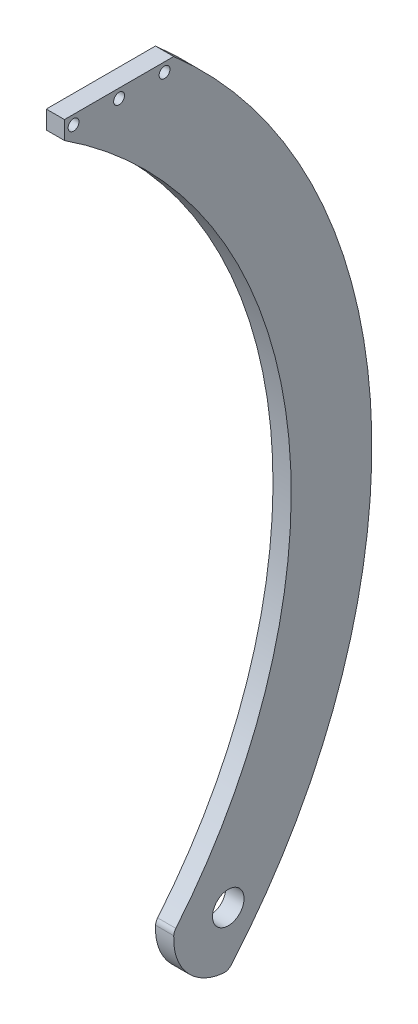
from build123d import *

# Parameters (mm, degrees)
SKETCH1_R                 = 5.5
BOSS_EXTRUDE1_DEPTH       = 6.35
F_6_CLEARANCE_HOLE1_D     = 3.7973
F_6_CLEARANCE_HOLE1_DEPTH = 6.35


with BuildPart() as part:
    # Sketch1 → Boss-Extrude1 (new body)
    with BuildSketch(Plane(origin=(0, 0, 0), x_dir=(0, 0, -1), z_dir=(1, 0, 0))):
        with BuildLine():
            Line((-19.05, 266.7), (19.05, 266.7))
            ThreePointArc((19.05, 266.7), (87.703033087, 128.539281009), (39.110598571, -17.88612161))
            ThreePointArc((39.110598571, -17.88612161), (37.900092771, -18.755241175), (36.426387255, -18.976341069))
            ThreePointArc((36.426387255, -18.976341069), (23.718766847, -12.493303526), (19.076049666, 0.995898429))
            ThreePointArc((19.076049666, 0.995898429), (19.289830149, 1.986417864), (19.804803607, 2.859133845))
            ThreePointArc((19.804803607, 2.859133845), (58.113146317, 140.316763388), (-19.05, 260.35))
            Line((-19.05, 260.35), (-19.05, 266.7))
        make_face()
        with Locations((38.1, 0)):
            Circle(SKETCH1_R, mode=Mode.SUBTRACT)
    extrude(amount=BOSS_EXTRUDE1_DEPTH)

    # #6 Clearance Hole1
    with Locations(Plane(origin=(6.35, 0, 0), x_dir=(0, 0, -1), z_dir=(1, 0, 0))):
        with Locations((-15.875, 263.525), (0, 263.525), (15.875, 263.525)):
            Hole(F_6_CLEARANCE_HOLE1_D / 2, depth=F_6_CLEARANCE_HOLE1_DEPTH)


solid = part.part
